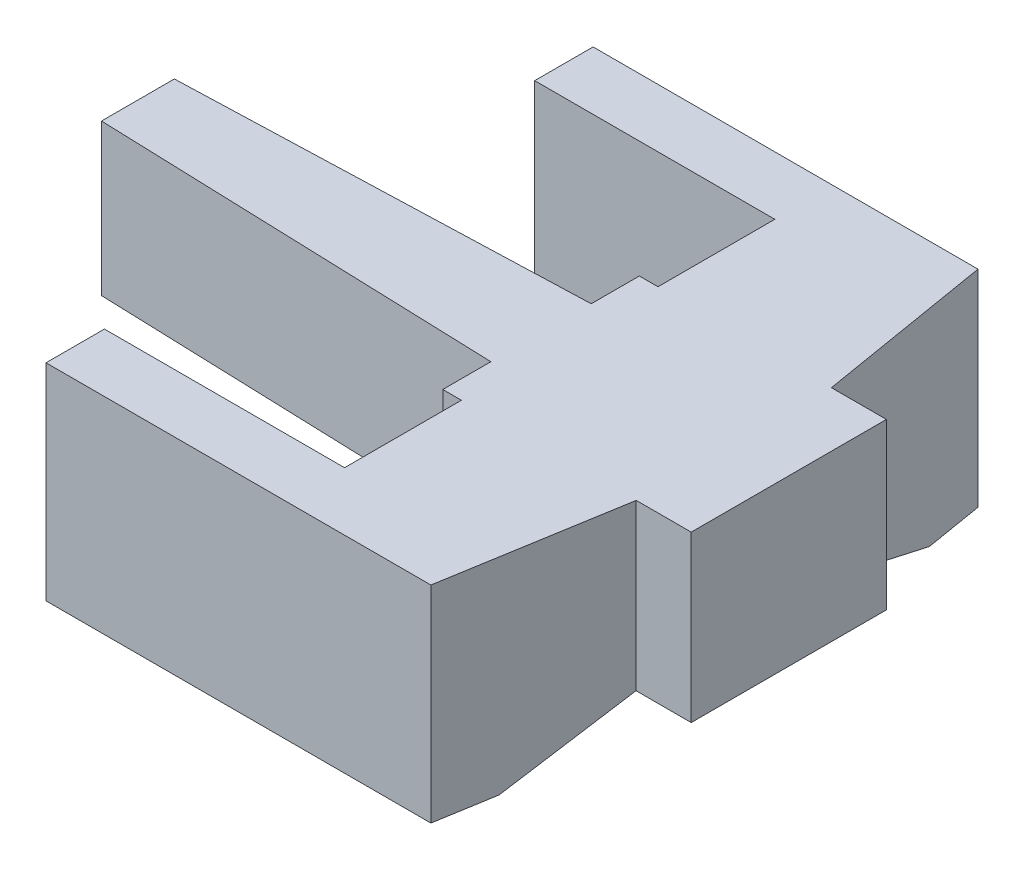
from build123d import *

# Parameters (mm, degrees)
BOSS_EXTRUDE1_DEPTH     = 15
SKETCH2_R               = 2.5
BOSS_EXTRUDE2_DEPTH     = 1
CUT_EXTRUDE1_DEPTH      = 3
CUT_EXTRUDE5_DEPTH      = 2
CUT_EXTRUDE5_DEPTH_BACK = 3
SKETCH5_W               = 1.356176493
SKETCH5_H               = 3
CUT_EXTRUDE6_DEPTH      = 3
CUT_EXTRUDE11_DEPTH     = 20
CUT_EXTRUDE12_DEPTH     = 1


with BuildPart() as part:
    # Sketch1 → Boss-Extrude1 (new body)
    with BuildSketch(Plane(origin=(0, 0, 0), x_dir=(1, 0, 0), z_dir=(0, 1, 0))):
        Polygon((53.231444905, 93.562909441), (55.368661466, 80.762909441), (59.368661466, 80.762909441), (59.368661466, 66.562909441), (55.368661466, 66.562909441), (53.231444905, 53.762909441), (25.231444905, 53.762909441), (25.231444905, 58.012909441), (42.701133317, 58.012909441), (42.701133317, 66.512909441), (41.344956824, 66.512909441), (41.344956824, 70.012909441), (12.018661466, 71.012909441), (12.018661466, 76.312909441), (41.344956824, 77.312909441), (41.344956824, 80.812909441), (42.701133317, 80.812909441), (42.701133317, 89.312909441), (25.231444905, 89.312909441), (25.231444905, 93.562909441), align=None)
    extrude(amount=BOSS_EXTRUDE1_DEPTH)

    # Sketch2 → Boss-Extrude2 (add)
    with BuildSketch(Plane.XZ):
        with Locations((42.701133317, -73.662909441)):
            Circle(SKETCH2_R)
    extrude(amount=BOSS_EXTRUDE2_DEPTH)

    # Sketch3 → Cut-Extrude1 (cut)
    with BuildSketch(Plane(origin=(0, 0, 0), x_dir=(-1, 0, 0), z_dir=(0, -1, 0))):
        with BuildLine():
            Line((-42.701133317, 80.812909441), (-55.368661466, 80.762909441))
            Line((-55.368661466, 80.762909441), (-59.368661466, 80.762909441))
            Line((-59.368661466, 80.762909441), (-59.368661466, 66.562909441))
            Line((-59.368661466, 66.562909441), (-41.344956824, 66.512909441))
            Line((-41.344956824, 66.512909441), (-41.344956824, 70.012909441))
            Line((-41.344956824, 70.012909441), (-41.344956824, 71.562722468))
            ThreePointArc((-41.344956824, 71.562722468), (-45.201133317, 73.662909441), (-41.344956824, 75.763096414))
            Line((-41.344956824, 75.763096414), (-41.344956824, 77.312909441))
            Line((-41.344956824, 77.312909441), (-41.344956824, 80.812909441))
            Line((-41.344956824, 80.812909441), (-42.701133317, 80.812909441))
        make_face()
    extrude(amount=-CUT_EXTRUDE1_DEPTH, mode=Mode.SUBTRACT)

    # Sketch4 → Cut-Extrude5 (cut, two sides)
    with BuildSketch(Plane.XZ) as cut_extrude5_sk:
        with BuildLine():
            Line((12.018661466, -76.312909441), (41.344956824, -77.312909441))
            Line((41.344956824, -77.312909441), (41.344956824, -77.220900459))
            Line((41.344956824, -77.220900459), (41.344956824, -75.763096414))
            ThreePointArc((41.344956824, -75.763096414), (40.201133317, -73.662909441), (41.344956824, -71.562722468))
            Line((41.344956824, -71.562722468), (41.344956824, -70.012909441))
            Line((41.344956824, -70.012909441), (12.018661466, -71.012909441))
            Line((12.018661466, -71.012909441), (12.018661466, -76.312909441))
        make_face()
    extrude(amount=CUT_EXTRUDE5_DEPTH, mode=Mode.SUBTRACT)
    extrude(cut_extrude5_sk.sketch, amount=-CUT_EXTRUDE5_DEPTH_BACK, mode=Mode.SUBTRACT)

    # Sketch5 → Cut-Extrude6 (cut)
    with BuildSketch(Plane.XY.offset(-66.512909441)):
        with Locations((42.023045071, 1.5)):
            Rectangle(SKETCH5_W, SKETCH5_H)
    extrude(amount=-CUT_EXTRUDE6_DEPTH, mode=Mode.SUBTRACT)

    # Sketch7 → Cut-Extrude11 (cut)
    with BuildSketch(Plane.ZY.offset(-42.701133317)):
        Polygon((-66.516671643, 0), (-67.290586566, 0), (-67.290586566, 3), (-66.512909441, 3), (-58.012909441, 0), align=None)
        Polygon((-89.312909441, 0), (-80.812909441, 0), (-79.713237651, 0), (-79.713237651, 3), (-80.812909441, 3), align=None)
    extrude(amount=-CUT_EXTRUDE11_DEPTH, mode=Mode.SUBTRACT)

    # Sketch11 → Cut-Extrude12 (cut)
    with BuildSketch(Plane.XZ.offset(-3)):
        with BuildLine():
            Line((41.344956824, -77.312909441), (41.344956824, -75.763096414))
            ThreePointArc((41.344956824, -75.763096414), (40.201133317, -73.662909441), (41.344956824, -71.562722468))
            Line((41.344956824, -71.562722468), (41.344956824, -70.012909441))
            Line((41.344956824, -70.012909441), (12.018661466, -71.012909441))
            Line((12.018661466, -71.012909441), (12.018661466, -76.312909441))
            Line((12.018661466, -76.312909441), (41.344956824, -77.312909441))
        make_face()
    extrude(amount=-CUT_EXTRUDE12_DEPTH, mode=Mode.SUBTRACT)


solid = part.part
